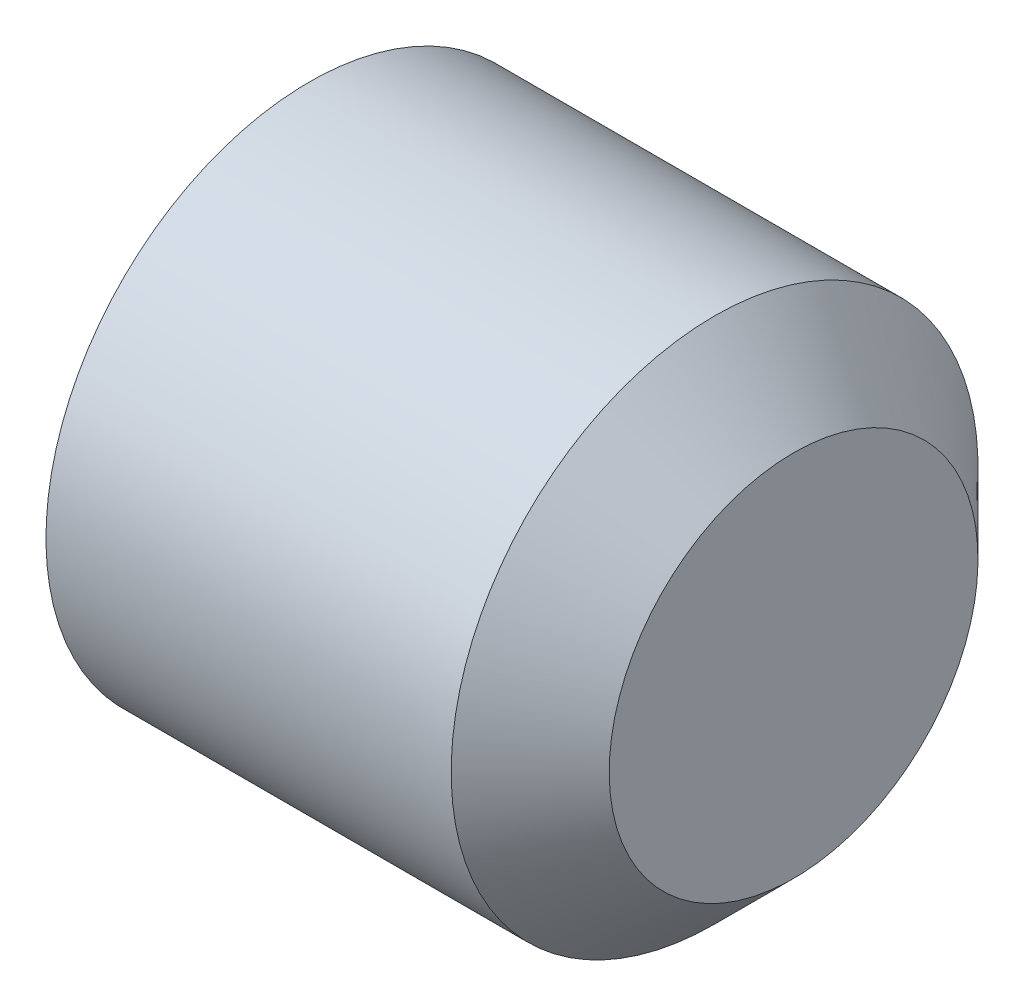
from build123d import *

# Parameters (mm, degrees)
SKETCH_1_W          = 5
SKETCH_1_H          = 2.5
CUT_EXTRUDE_1_DEPTH = 1.5
CHAMFER_1_SIZE      = 0.75
CHAMFER_2_SIZE      = 0.7
CHAMFER_2_SIZE2     = 0.404145188
FILLET_1_R          = 0.1


with BuildPart() as part:
    # Эскиз1 → Повернуть1 (revolve)
    with BuildSketch(Plane(origin=(0, 0, 0), x_dir=(-1, 0, 0), z_dir=(0, 0, -1))):
        with Locations((-2.5, 1.25)):
            Rectangle(SKETCH_1_W, SKETCH_1_H)
    revolve(axis=Axis((5, 0, 0), (-1, 0, 0)))

    # Эскиз2 → Вырез-Вытянуть1 (cut)
    with BuildSketch(Plane.ZY):
        Polygon((0.721687836, -1.25), (1.443375673, 0), (0.721687836, 1.25), (-0.721687836, 1.25), (-1.443375673, 0), (-0.721687836, -1.25), align=None)
    extrude(amount=-CUT_EXTRUDE_1_DEPTH, mode=Mode.SUBTRACT)

    # Фаска1
    chamfer_1_edges = [part.edges().sort_by_distance(p)[0] for p in [
        (5, -2.5, 0),
    ]]
    chamfer(chamfer_1_edges, length=CHAMFER_1_SIZE)

    # Фаска2
    chamfer_2_edges = [part.edges().sort_by_distance(p)[0] for p in [
        (0, -2.5, 0),
    ]]
    chamfer_2_side = [part.faces().sort_by_distance(p)[0] for p in [
        (0, -2.429289322, 0),
    ]]
    chamfer(chamfer_2_edges, length=CHAMFER_2_SIZE, length2=CHAMFER_2_SIZE2, reference=chamfer_2_side[0])

    # Скругление1
    fillet_1_edges = [part.edges().sort_by_distance(p)[0] for p in [
        (1.5, -1.25, 0),
        (1.5, -0.625, -1.082531755),
        (1.5, 0.625, -1.082531755),
        (1.5, 1.25, 0),
        (1.5, 0.625, 1.082531755),
        (1.5, -0.625, 1.082531755),
        (0, -1.25, 0),
        (0, -0.625, 1.082531755),
        (0, 0.625, 1.082531755),
        (0, 1.25, 0),
        (0, 0.625, -1.082531755),
        (0, -0.625, -1.082531755),
        (0, -1.8, 0),
    ]]
    fillet(fillet_1_edges, radius=FILLET_1_R)


solid = part.part
